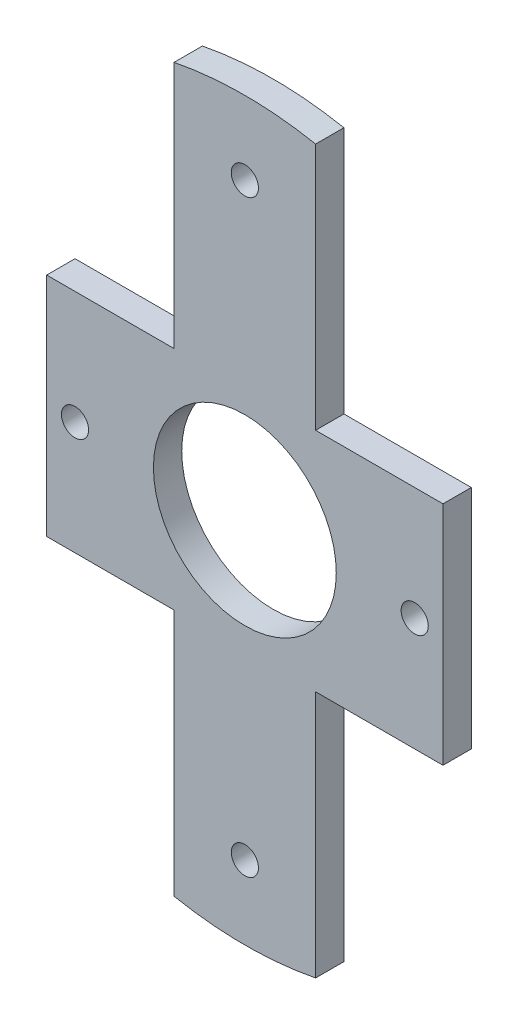
from build123d import *

# Parameters (mm, degrees)
SKETCH1_R           = 16.15
SKETCH1_R_2         = 2.4
BOSS_EXTRUDE1_DEPTH = 5


with BuildPart() as part:
    # Sketch1 → Boss-Extrude1 (new body)
    with BuildSketch(Plane.XY):
        with BuildLine():
            Line((12.5, 20), (35, 20))
            Line((35, 20), (35, 0))
            Line((35, 0), (35, -20))
            Line((35, -20), (12.5, -20))
            Line((12.5, -20), (12.5, -63.786754111))
            ThreePointArc((12.5, -63.786754111), (0, -65), (-12.5, -63.786754111))
            Line((-12.5, -63.786754111), (-12.5, -20))
            Line((-12.5, -20), (-35, -20))
            Line((-35, -20), (-35, 20))
            Line((-35, 20), (-12.5, 20))
            Line((-12.5, 20), (-12.5, 63.786754111))
            ThreePointArc((-12.5, 63.786754111), (0, 65), (12.5, 63.786754111))
            Line((12.5, 63.786754111), (12.5, 20))
        make_face()
        Circle(SKETCH1_R, mode=Mode.SUBTRACT)
        with Locations((0, 52)):
            Circle(SKETCH1_R_2, mode=Mode.SUBTRACT)
        with Locations((30, 0)):
            Circle(SKETCH1_R_2, mode=Mode.SUBTRACT)
        with Locations((0, -52)):
            Circle(SKETCH1_R_2, mode=Mode.SUBTRACT)
        with Locations((-30, 0)):
            Circle(SKETCH1_R_2, mode=Mode.SUBTRACT)
    extrude(amount=BOSS_EXTRUDE1_DEPTH)


solid = part.part
